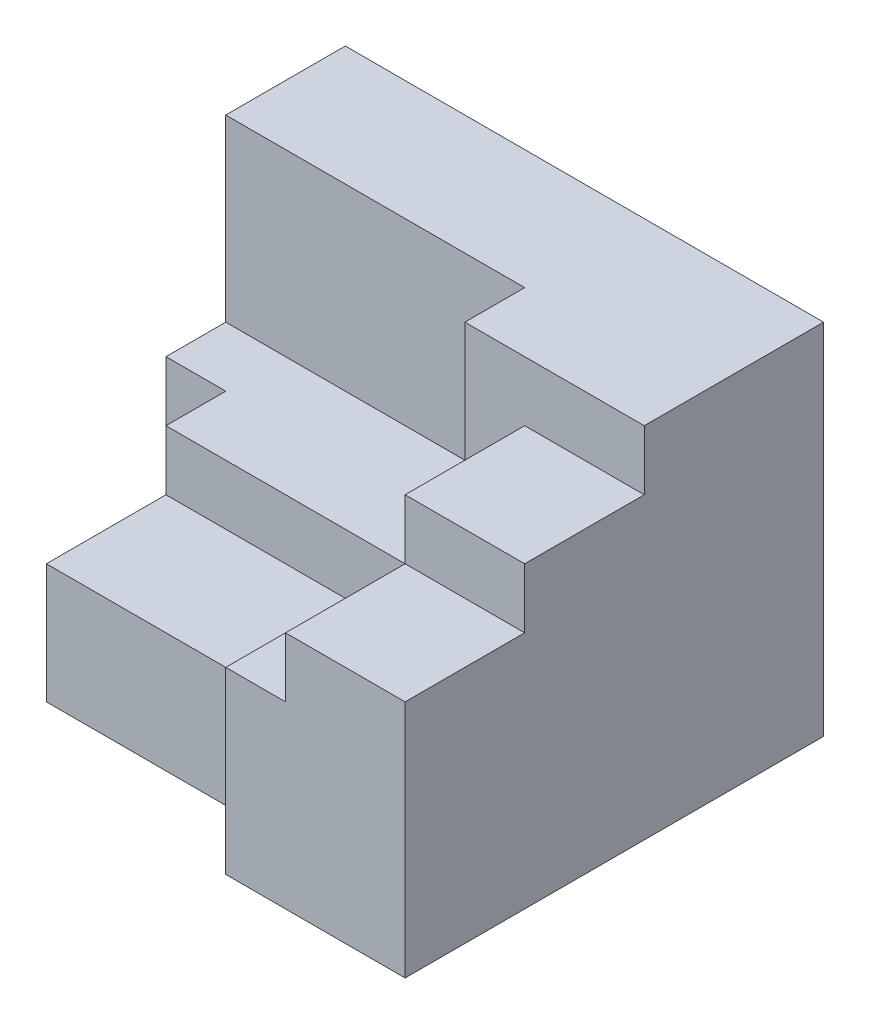
from build123d import *

# Parameters (mm, degrees)
SKETCH1_W           = 8
SKETCH1_H           = 7
BOSS_EXTRUDE1_DEPTH = 6
CUT_EXTRUDE1_DEPTH  = 60
CUT_EXTRUDE2_DEPTH  = 3
SKETCH5_W           = 4
SKETCH5_H           = 2
CUT_EXTRUDE3_DEPTH  = 1
SKETCH6_W           = 3.001059972
SKETCH6_H           = 4.860975679
CUT_EXTRUDE4_DEPTH  = 1
SKETCH7_W           = 2
SKETCH7_H           = 2
CUT_EXTRUDE5_DEPTH  = 1


with BuildPart() as part:
    # Sketch1 → Boss-Extrude1 (new body)
    with BuildSketch(Plane(origin=(0, 0, 0), x_dir=(1, 0, 0), z_dir=(0, 1, 0))):
        Rectangle(SKETCH1_W, SKETCH1_H)
    extrude(amount=BOSS_EXTRUDE1_DEPTH)

    # Sketch2 → Cut-Extrude1 (cut)
    with BuildSketch(Plane(origin=(0, 6, 0), x_dir=(1, 0, 0), z_dir=(0, 1, 0))):
        Polygon((-4, 0.5), (-3, 0.5), (-3, -2.5), (1, -2.5), (1, -3.5), (-4, -3.5), align=None)
    extrude(amount=-CUT_EXTRUDE1_DEPTH, mode=Mode.SUBTRACT)

    # Sketch4 → Cut-Extrude2 (cut)
    with BuildSketch(Plane(origin=(0, 6, 0), x_dir=(1, 0, 0), z_dir=(0, 1, 0))):
        Polygon((-4, 1.5), (1, 1.5), (1, 0.5), (2, 0.5), (2, -4.455907127), (-4, -3.689508324), align=None)
    extrude(amount=-CUT_EXTRUDE2_DEPTH, mode=Mode.SUBTRACT)

    # Sketch5 → Cut-Extrude3 (cut)
    with BuildSketch(Plane(origin=(0, 3, 0), x_dir=(1, 0, 0), z_dir=(0, 1, 0))):
        with Locations((-1, -1.5)):
            Rectangle(SKETCH5_W, SKETCH5_H)
    extrude(amount=-CUT_EXTRUDE3_DEPTH, mode=Mode.SUBTRACT)

    # Sketch6 → Cut-Extrude4 (cut)
    with BuildSketch(Plane(origin=(0, 6, 0), x_dir=(1, 0, 0), z_dir=(0, 1, 0))):
        with Locations((3.500529986, -1.93048784)):
            Rectangle(SKETCH6_W, SKETCH6_H)
    extrude(amount=-CUT_EXTRUDE4_DEPTH, mode=Mode.SUBTRACT)

    # Sketch7 → Cut-Extrude5 (cut)
    with BuildSketch(Plane(origin=(0, 5, 0), x_dir=(1, 0, 0), z_dir=(0, 1, 0))):
        with Locations((3, -2.5)):
            Rectangle(SKETCH7_W, SKETCH7_H)
    extrude(amount=-CUT_EXTRUDE5_DEPTH, mode=Mode.SUBTRACT)


solid = part.part
